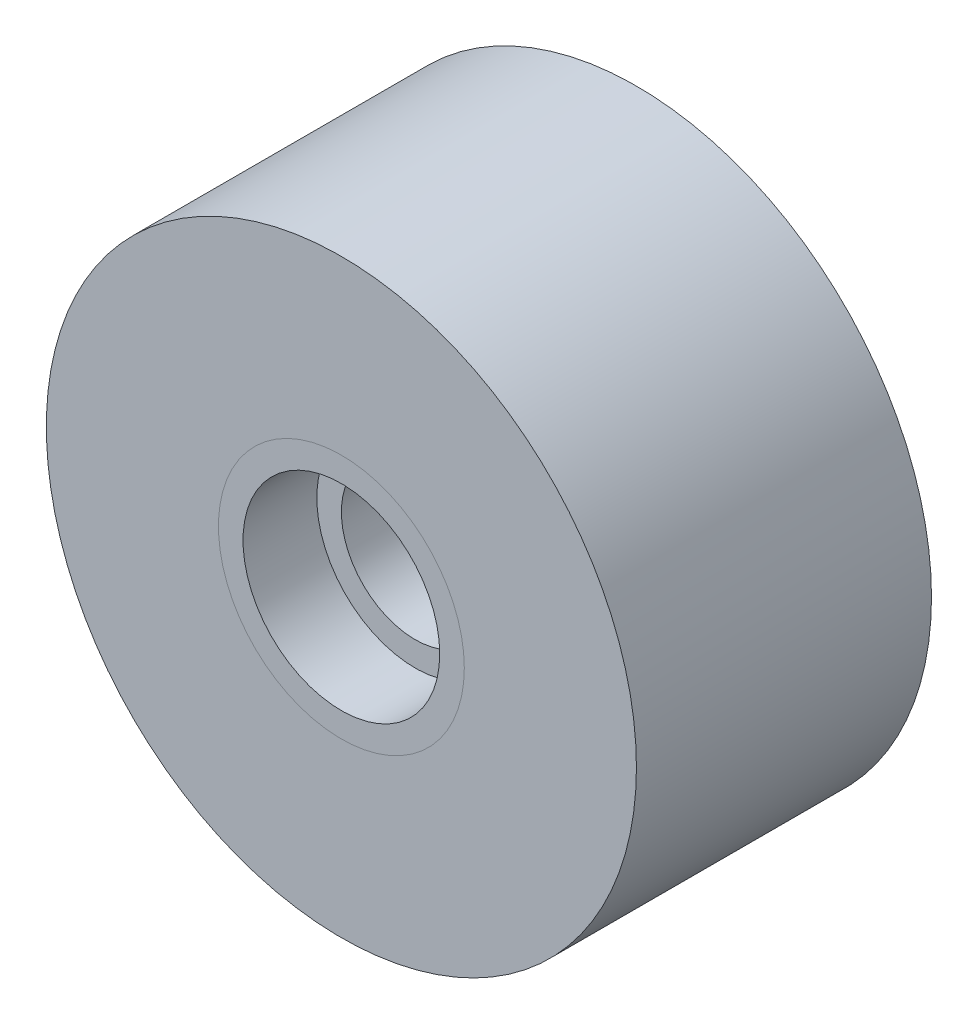
from build123d import *

# Parameters (mm, degrees)
SKETCH_1_R      = 12
SKETCH_1_R_2    = 5
EXTRUDE_1_DEPTH = 6
SKETCH_1_3_R    = 5
SKETCH_1_3_R_2  = 4
EXTRUDE_2_DEPTH = 6
SKETCH_1_4_R    = 4
SKETCH_1_4_R_2  = 3
EXTRUDE_3_DEPTH = 3


with BuildPart() as part:
    # 草图1 → 凸台-拉伸1 (new, symmetric)
    with BuildSketch(Plane.XY):
        Circle(SKETCH_1_R)
        Circle(SKETCH_1_R_2, mode=Mode.SUBTRACT)
    extrude(amount=EXTRUDE_1_DEPTH, both=True)


with BuildPart() as body_2:
    # 草图1<3> → 凸台-拉伸2 (new, symmetric)
    with BuildSketch(Plane.XY):
        Circle(SKETCH_1_3_R)
        Circle(SKETCH_1_3_R_2, mode=Mode.SUBTRACT)
    extrude(amount=EXTRUDE_2_DEPTH, both=True)

    # 草图1<4> → 凸台-拉伸3 (add, symmetric)
    with BuildSketch(Plane.XY):
        Circle(SKETCH_1_4_R)
        Circle(SKETCH_1_4_R_2, mode=Mode.SUBTRACT)
    extrude(amount=EXTRUDE_3_DEPTH, both=True)


solid = Compound([part.part, body_2.part])
